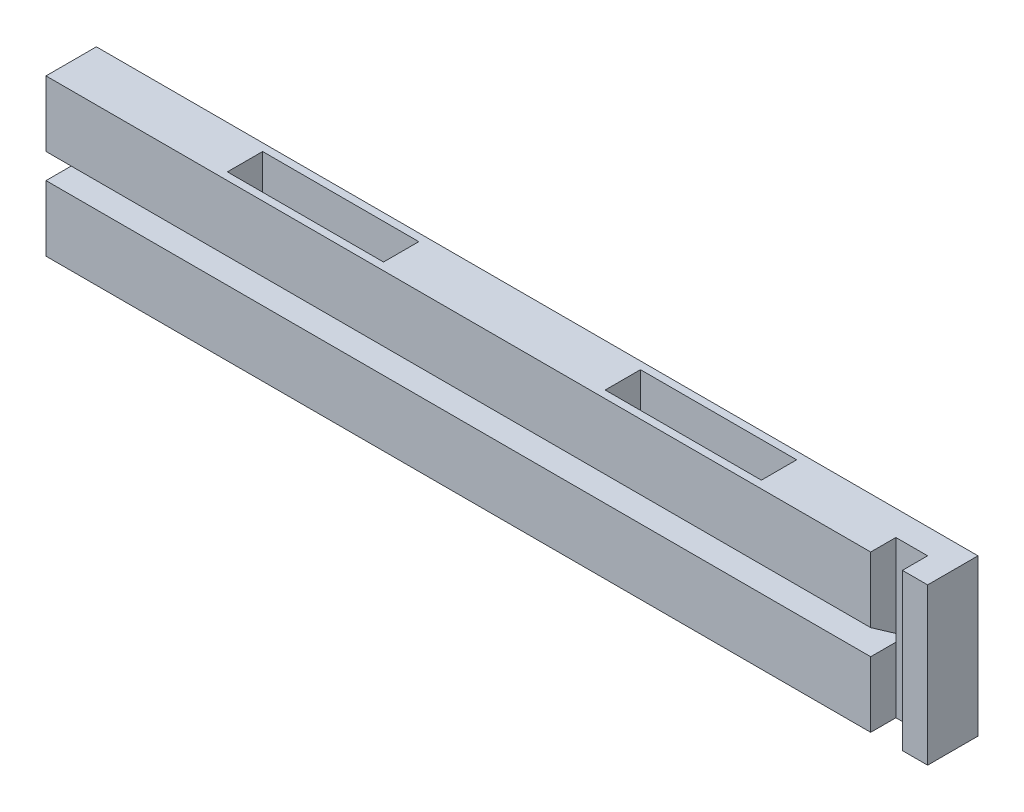
from build123d import *

# Parameters (mm, degrees)
ESBO_O1_W                = 175
ESBO_O1_H                = 31
RESSALTO_EXTRUS_O1_DEPTH = 10
ESBO_O2_W                = 31
ESBO_O2_H                = 7
CORTE_EXTRUS_O1_DEPTH    = 10.5
ESBO_O3_W                = 31
ESBO_O3_H                = 7
CORTE_EXTRUS_O2_DEPTH    = 10.5
ESBO_O5_R                = 1.5
CORTE_EXTRUS_O4_DEPTH    = 8
ESBO_O7_W                = 6.3
ESBO_O7_H                = 31
CORTE_EXTRUS_O6_DEPTH    = 5
CORTE_EXTRUS_O7_DEPTH    = 163.7


with BuildPart() as part:
    # Esboço1 → Ressalto-extrusão1 (new body)
    with BuildSketch(Plane.XY):
        Rectangle(ESBO_O1_W, ESBO_O1_H)
    extrude(amount=RESSALTO_EXTRUS_O1_DEPTH)

    # Esboço2 → Corte-extrusão1 (cut)
    with BuildSketch(Plane(origin=(0, 15.5, 0), x_dir=(1, 0, 0), z_dir=(0, 1, 0))):
        with Locations((-37.5, -5)):
            Rectangle(ESBO_O2_W, ESBO_O2_H)
        with Locations((37.5, -5)):
            Rectangle(ESBO_O2_W, ESBO_O2_H)
    extrude(amount=-CORTE_EXTRUS_O1_DEPTH, mode=Mode.SUBTRACT)

    # Esboço3 → Corte-extrusão2 (cut)
    with BuildSketch(Plane.XZ.offset(15.5)):
        with Locations((-37.5, 5)):
            Rectangle(ESBO_O3_W, ESBO_O3_H)
        with Locations((37.5, 5)):
            Rectangle(ESBO_O3_W, ESBO_O3_H)
    extrude(amount=-CORTE_EXTRUS_O2_DEPTH, mode=Mode.SUBTRACT)

    # Esboço5 → Corte-extrusão4 (cut)
    with BuildSketch(Plane.ZY.offset(87.5)):
        with Locations((5, 10.5)):
            Circle(ESBO_O5_R)
        with Locations((5, -10.5)):
            Circle(ESBO_O5_R)
    extrude(amount=-CORTE_EXTRUS_O4_DEPTH, mode=Mode.SUBTRACT)

    # Esboço7 → Corte-extrusão6 (cut)
    with BuildSketch(Plane.XY.offset(10)):
        with Locations((79.35, 0)):
            Rectangle(ESBO_O7_W, ESBO_O7_H)
    extrude(amount=-CORTE_EXTRUS_O6_DEPTH, mode=Mode.SUBTRACT)

    # Esboço8 → Corte-extrusão7 (cut)
    with BuildSketch(Plane.ZY.offset(87.5)):
        Polygon((10, 2.5), (2.859259966, -2.5), (10, -2.5), align=None)
    extrude(amount=-CORTE_EXTRUS_O7_DEPTH, mode=Mode.SUBTRACT)


solid = part.part
